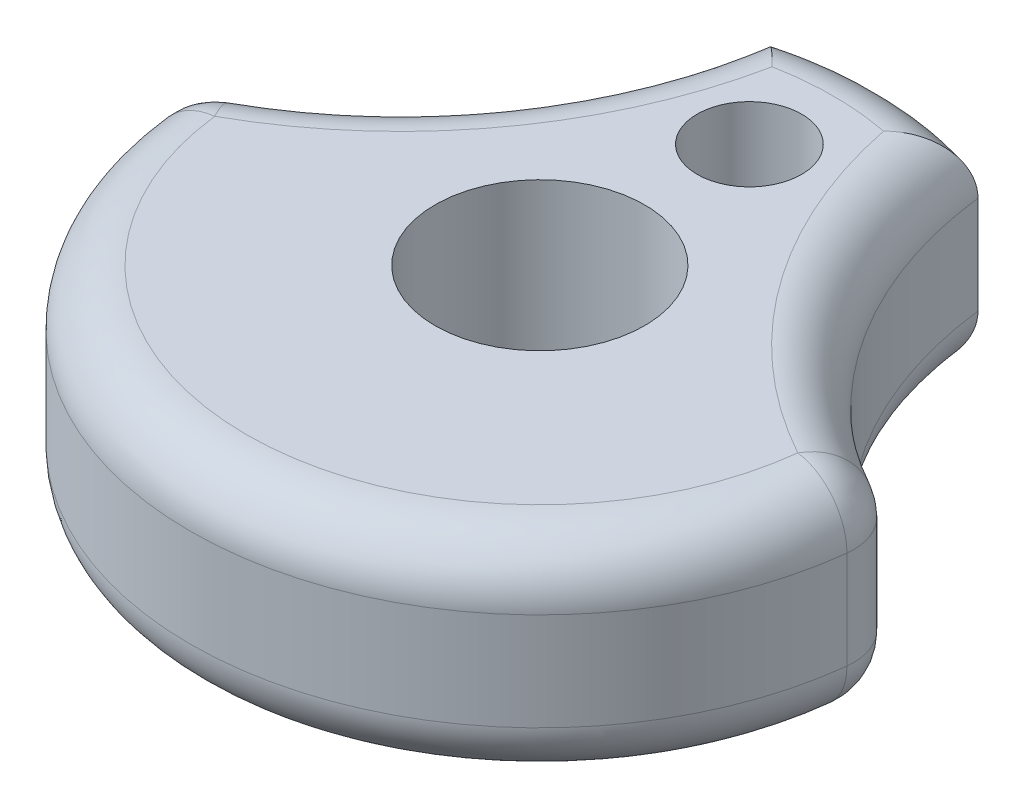
from build123d import *

# Parameters (mm, degrees)
BOSS_EXTRUDE1_DEPTH = 9.525
SKETCH2_R           = 4.7625
SKETCH2_R_2         = 2.3749
CUT_EXTRUDE1_DEPTH  = 10.525
FILLET4_R           = 2.54


with BuildPart() as part:
    # Sketch1 → Boss-Extrude1 (new body)
    with BuildSketch(Plane(origin=(0, 0, 0), x_dir=(1, 0, 0), z_dir=(0, 1, 0))):
        with BuildLine():
            ThreePointArc((-4.7752, 15.139785004), (-8.330712377, 6.107698439), (-15.875, 0))
            ThreePointArc((-15.875, 0), (0, -15.875), (15.875, 0))
            ThreePointArc((15.875, 0), (8.330712377, 6.107698439), (4.7752, 15.139785004))
            ThreePointArc((4.7752, 15.139785004), (0, 15.875), (-4.7752, 15.139785004))
        make_face()
    extrude(amount=BOSS_EXTRUDE1_DEPTH)

    # Sketch2 → Cut-Extrude1 (cut, through all)
    with BuildSketch(Plane(origin=(0, 9.525, 0), x_dir=(1, 0, 0), z_dir=(0, 1, 0))):
        Circle(SKETCH2_R)
        with Locations((0, 9.525)):
            Circle(SKETCH2_R_2)
    extrude(amount=-CUT_EXTRUDE1_DEPTH, mode=Mode.SUBTRACT)

    # Fillet4
    fillet4_edges = [part.edges().sort_by_distance(p)[0] for p in [
        (0, 9.525, 15.875),
        (8.330712377, 9.525, -6.107698439),
        (0, 9.525, -15.875),
        (8.330712377, 0, -6.107698439),
        (0, 0, 15.875),
        (-8.330712377, 0, -6.107698439),
        (0, 0, -15.875),
        (15.875, 4.7625, 0),
        (-15.875, 4.7625, 0),
        (-8.330712377, 9.525, -6.107698439),
    ]]
    fillet(fillet4_edges, radius=FILLET4_R)


solid = part.part
